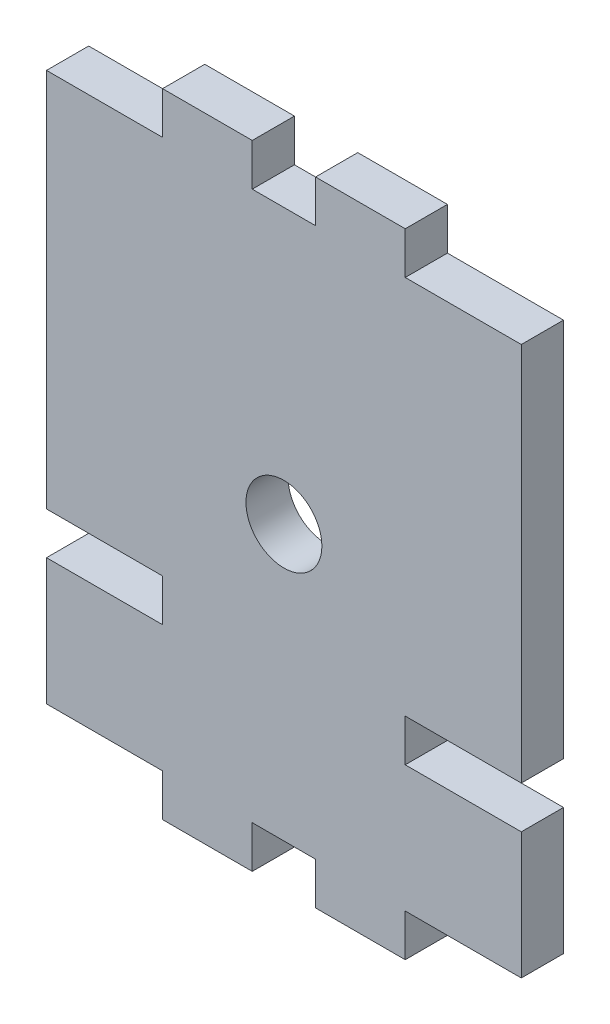
from build123d import *

# Parameters (mm, degrees)
SKETCH1_R           = 3.6
BOSS_EXTRUDE1_DEPTH = 4


with BuildPart() as part:
    # Sketch1 → Boss-Extrude1 (new body)
    with BuildSketch(Plane.XY):
        Polygon((11, 4), (11, 0), (19.5, 0), (19.5, 4), (25.5, 4), (25.5, 0), (34, 0), (34, 4), (45, 4), (45, 16), (34, 16), (34, 20), (45, 20), (45, 56), (34, 56), (34, 60), (25.5, 60), (25.5, 56), (19.5, 56), (19.5, 60), (11, 60), (11, 56), (0, 56), (0, 20), (11, 20), (11, 16), (0, 16), (0, 4), align=None)
        with Locations((22.5, 30)):
            Circle(SKETCH1_R, mode=Mode.SUBTRACT)
    extrude(amount=BOSS_EXTRUDE1_DEPTH)


solid = part.part
